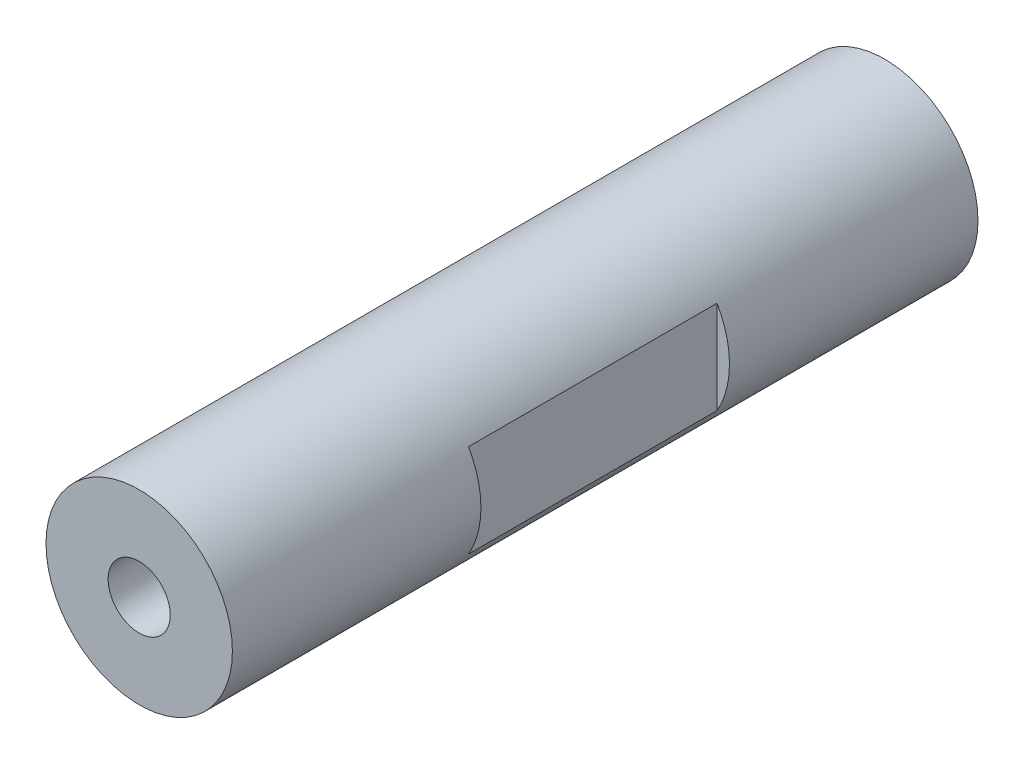
from build123d import *

# Parameters (mm, degrees)
SKETCH_1_R          = 7.5
EXTRUDE_1_DEPTH     = 30
SKETCH_2_W          = 2
SKETCH_2_H          = 20
CUT_EXTRUDE_1_DEPTH = 10


with BuildPart() as part:
    # 草图1 → 凸台-拉伸1 (new body, symmetric)
    with BuildSketch(Plane.XY):
        Circle(SKETCH_1_R)
    extrude(amount=EXTRUDE_1_DEPTH, both=True)

    # 草图2 → 切除-拉伸1 (cut, symmetric)
    with BuildSketch(Plane(origin=(0, 0, 0), x_dir=(1, 0, 0), z_dir=(0, 1, 0))):
        with Locations((-7.5, 0)):
            Rectangle(SKETCH_2_W, SKETCH_2_H)
        with Locations((7.5, 0)):
            Rectangle(SKETCH_2_W, SKETCH_2_H)
    extrude(amount=CUT_EXTRUDE_1_DEPTH, both=True, mode=Mode.SUBTRACT)

    # 草图5 → M6 螺纹孔1 (revolve, cut)
    with BuildSketch(Plane(origin=(0, 0, -30), x_dir=(0, 1, 0), z_dir=(1, 0, 0))):
        Polygon((0, 0), (0, 16.502151548), (2.5, 15), (2.5, 0), align=None)
    hole_wizard_m6_1 = revolve(axis=Axis((0, 0, -36.35), (0, 0, 1)), mode=Mode.SUBTRACT)

    # 镜向1: M6 螺纹孔1 across plane
    add(hole_wizard_m6_1.mirror(Plane.XY), mode=Mode.SUBTRACT)


solid = part.part
